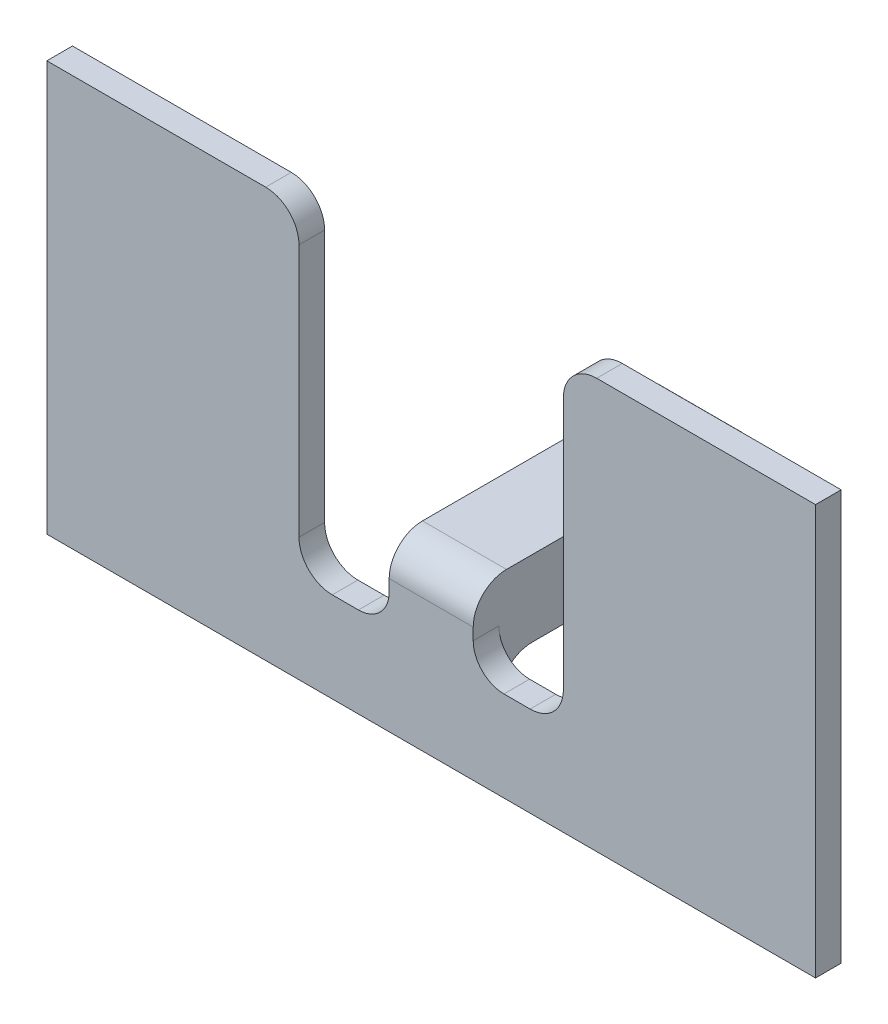
from build123d import *

# Parameters (mm, degrees)
SKETCH1_W           = 75
SKETCH1_H           = 40
BOSS_EXTRUDE1_DEPTH = 2.5
CUT_EXTRUDE1_DEPTH  = 10
SKETCH2_3_W         = 8.2
SKETCH2_3_H         = 7.4
BOSS_EXTRUDE2_DEPTH = 23.814
FILLET1_R           = 3.25
FILLET2_R           = 3


with BuildPart() as part:
    # Sketch1 → Boss-Extrude1 (new body)
    with BuildSketch(Plane.XY):
        Rectangle(SKETCH1_W, SKETCH1_H)
    extrude(amount=BOSS_EXTRUDE1_DEPTH)

    # Sketch2 → Cut-Extrude1 (cut)
    with BuildSketch(Plane.XY):
        Polygon((12.9, -11.2), (12.9, 20), (-12.9, 20), (-12.9, -11.2), (-4.1, -11.2), (-4.1, -3.8), (4.1, -3.8), (4.1, -11.2), align=None)
    extrude(amount=CUT_EXTRUDE1_DEPTH, mode=Mode.SUBTRACT)

    # Sketch2_3 → Boss-Extrude2 (add)
    with BuildSketch(Plane.XY):
        with Locations((0, -7.5)):
            Rectangle(SKETCH2_3_W, SKETCH2_3_H)
    extrude(amount=-BOSS_EXTRUDE2_DEPTH)

    # Fillet1
    fillet1_edges = [part.edges().sort_by_distance(p)[0] for p in [
        (-12.9, 20, 1.25),
        (-12.9, -11.2, 1.25),
        (0, -3.8, 2.5),
        (0, -11.2, 0),
        (12.9, -11.2, 1.25),
        (12.9, 20, 1.25),
        (0, -11.2, -23.814),
    ]]
    fillet(fillet1_edges, radius=FILLET1_R)

    # Fillet2
    fillet2_edges = [part.edges().sort_by_distance(p)[0] for p in [
        (-4.1, -11.2, 1.25),
        (4.1, -11.2, 1.25),
    ]]
    fillet(fillet2_edges, radius=FILLET2_R)


solid = part.part
